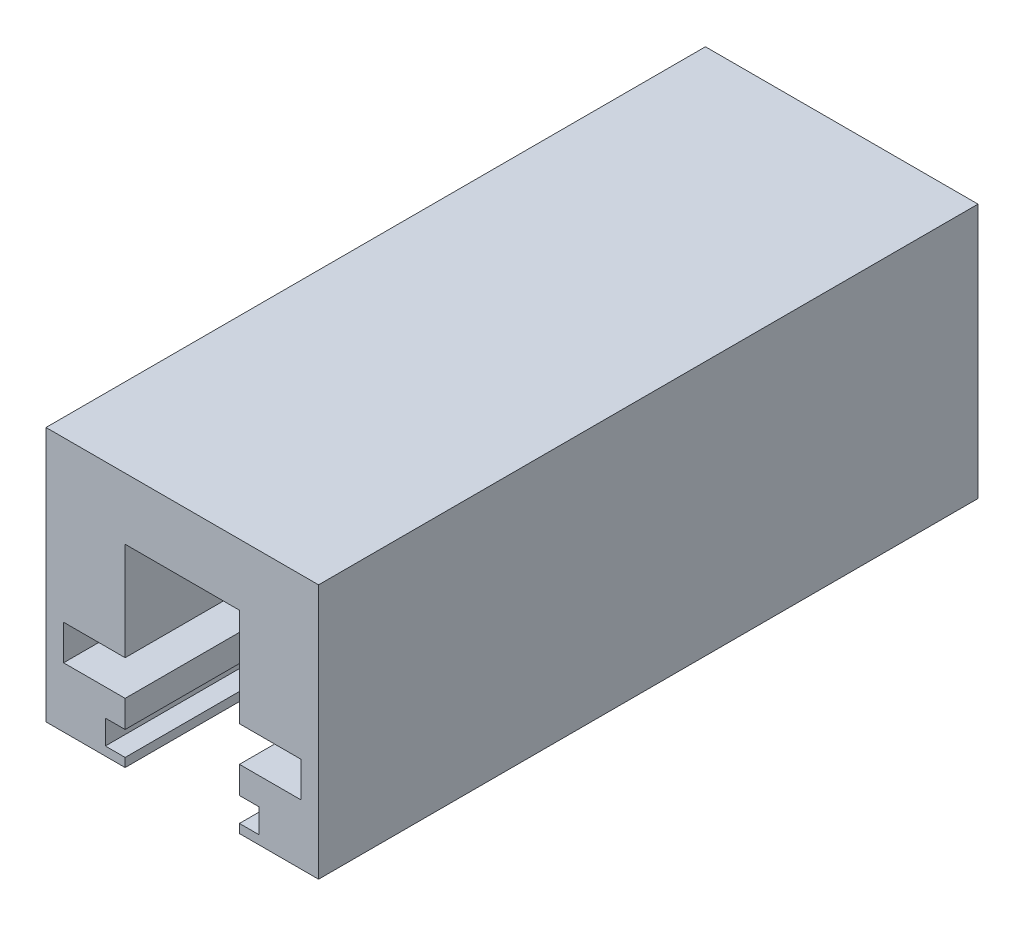
from build123d import *

# Parameters (mm, degrees)
BOSS_EXTRUDE2_DEPTH = 75


with BuildPart() as part:
    # Sketch1 → Boss-Extrude2 (new body)
    with BuildSketch(Plane.XY):
        Polygon((-31, 29), (-31, 0), (-22, 0), (-22, 1), (-24.25, 1), (-24.25, 3.75), (-22, 3.75), (-22, 6.82), (-29, 6.82), (-29, 10.82), (-22, 10.82), (-22, 22), (-9, 22), (-9, 10.82), (-2, 10.82), (-2, 6.82), (-9, 6.82), (-9, 3.75), (-6.75, 3.75), (-6.75, 1), (-9, 1), (-9, 0), (0, 0), (0, 29), align=None)
    extrude(amount=BOSS_EXTRUDE2_DEPTH)


solid = part.part
